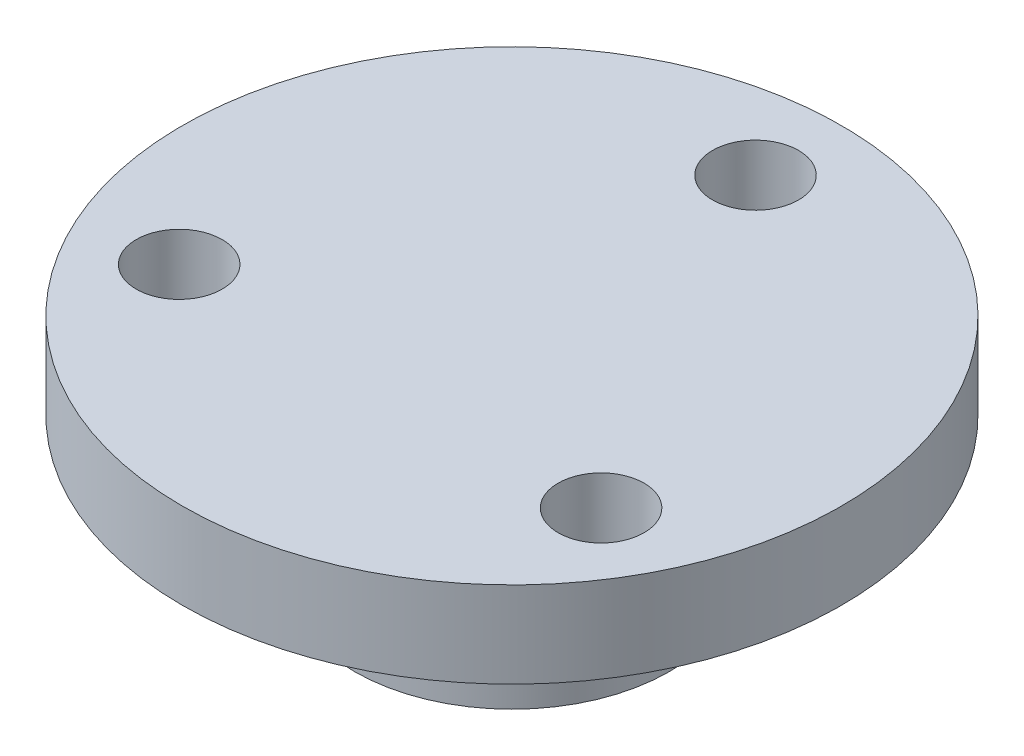
from build123d import *

# Parameters (mm, degrees)
SKETCH1_R                   = 5.5
SKETCH1_W                   = 4
SKETCH1_H                   = 2
BOSS_EXTRUDE1_DEPTH         = 5
SKETCH2_R                   = 11.5
BOSS_EXTRUDE2_DEPTH         = 3
SKETCH3_R                   = 1.5
WHEEL_SCREWS_DEPTH          = 3
WHEEL_SCREW_PATTERN_COUNT   = 3
SKETCH5_R                   = 0.95
MOTOR_SCREW_HOLE_DEPTH      = 3
MOTOR_SCREW_HOLE_DEPTH_BACK = 8.474829283


with BuildPart() as part:
    # Sketch1 → Boss-Extrude1 (new body)
    with BuildSketch(Plane(origin=(0, 0, 0), x_dir=(1, 0, 0), z_dir=(0, 1, 0))):
        Circle(SKETCH1_R)
        with BuildLine():
            Line((-1.095, -1.025170717), (1.095, -1.025170717))
            ThreePointArc((1.095, -1.025170717), (0, 1.5), (-1.095, -1.025170717))
        make_face(mode=Mode.SUBTRACT)
        with Locations((0, -3.025170717)):
            Rectangle(SKETCH1_W, SKETCH1_H, mode=Mode.SUBTRACT)
    extrude(amount=BOSS_EXTRUDE1_DEPTH)

    # Sketch2 → Boss-Extrude2 (add)
    with BuildSketch(Plane(origin=(0, 5, 0), x_dir=(1, 0, 0), z_dir=(0, 1, 0))):
        Circle(SKETCH2_R)
    extrude(amount=BOSS_EXTRUDE2_DEPTH)

    # Sketch3 → wheel_screws (cut)
    with BuildSketch(Plane.XZ.offset(-5)):
        with Locations((0, -8.5)):
            Circle(SKETCH3_R)
    wheel_screws = extrude(amount=-WHEEL_SCREWS_DEPTH, mode=Mode.SUBTRACT)

    # wheel_screw_pattern: wheel_screws ×3 about axis
    wheel_screw_pattern_axis = Axis((0, 0, 0), (0, 1, 0))
    for i in range(1, WHEEL_SCREW_PATTERN_COUNT):
        add(wheel_screws.rotate(wheel_screw_pattern_axis, i * 360 / WHEEL_SCREW_PATTERN_COUNT), mode=Mode.SUBTRACT)

    # Sketch5 → motor_screw_hole (cut, two sides)
    with BuildSketch(Plane(origin=(0, 0, 4.025170717), x_dir=(-1, 0, 0), z_dir=(0, 0, -1))) as motor_screw_hole_sk:
        with Locations((0, 2.5)):
            Circle(SKETCH5_R)
    extrude(amount=MOTOR_SCREW_HOLE_DEPTH, mode=Mode.SUBTRACT)
    extrude(motor_screw_hole_sk.sketch, amount=-MOTOR_SCREW_HOLE_DEPTH_BACK, mode=Mode.SUBTRACT)


solid = part.part
